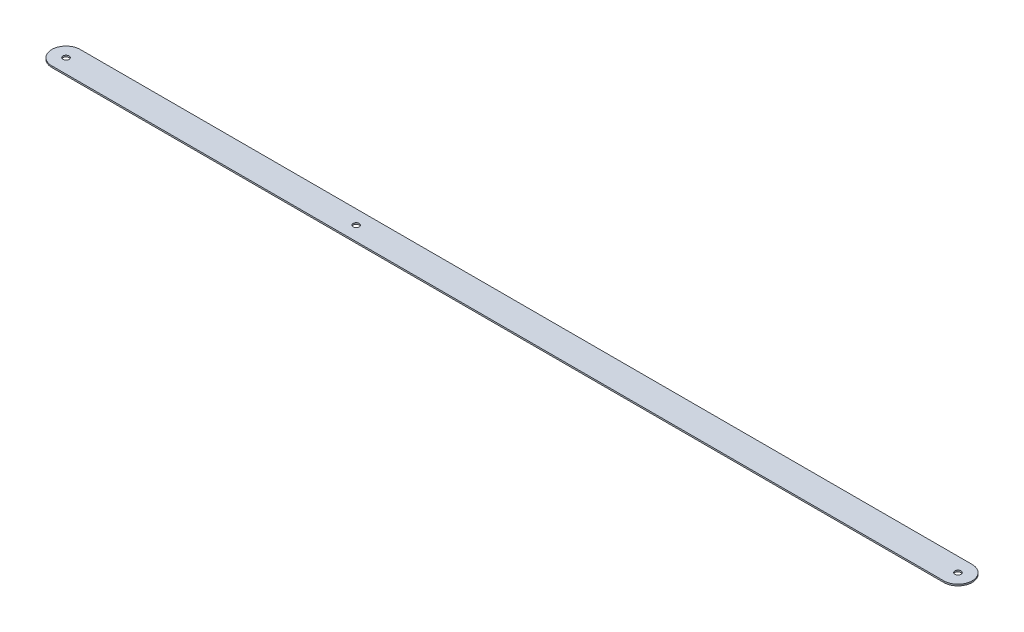
from build123d import *

# Parameters (mm, degrees)
SKETCH1_R           = 3
BOSS_EXTRUDE1_DEPTH = 1.5


with BuildPart() as part:
    # Sketch1 → Boss-Extrude1 (new body)
    with BuildSketch(Plane(origin=(0, 0, 0), x_dir=(1, 0, 0), z_dir=(0, 1, 0))):
        with BuildLine():
            Line((0, 14), (880.4, 14))
            ThreePointArc((880.4, 14), (894.4, 0), (880.4, -14))
            Line((880.4, -14), (0, -14))
            ThreePointArc((0, -14), (-14, 0), (0, 14))
        make_face()
        with Locations((880.4, 0)):
            Circle(SKETCH1_R, mode=Mode.SUBTRACT)
        Circle(SKETCH1_R, mode=Mode.SUBTRACT)
        with Locations((286.33, 0)):
            Circle(SKETCH1_R, mode=Mode.SUBTRACT)
    extrude(amount=BOSS_EXTRUDE1_DEPTH)


solid = part.part
